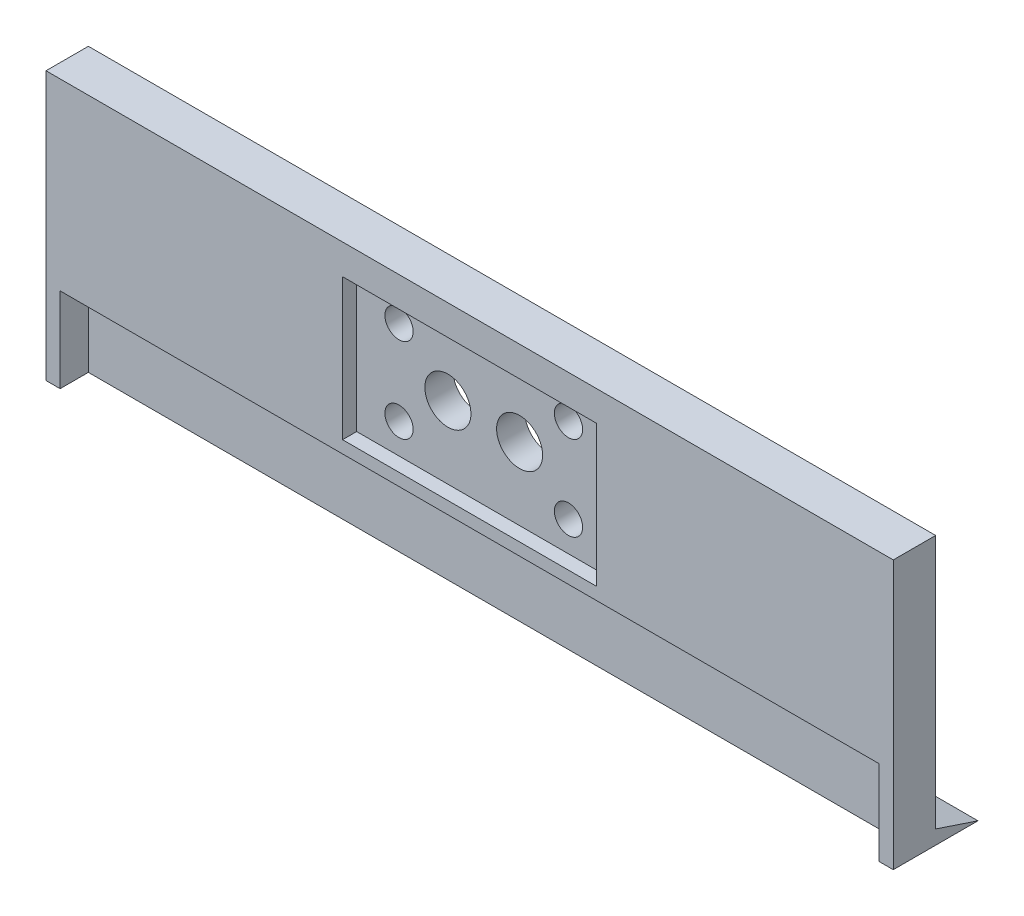
from build123d import *

# Parameters (mm, degrees)
ESQUISSE1_W             = 300
ESQUISSE1_H             = 95
BOSS_EXTRU_1_DEPTH      = 5
BOSS_EXTRU_2_DEPTH      = 300
BOSS_EXTRU_3_DEPTH      = 10
ESQUISSE6_R             = 8.15
ESQUISSE6_R_2           = 5
ENL_V_MAT_EXTRU_2_DEPTH = 16
ESQUISSE7_W             = 290
ESQUISSE7_H             = 23.020862504
ENL_V_MAT_EXTRU_3_DEPTH = 30
ESQUISSE9_W             = 90
ESQUISSE9_H             = 50
ENL_V_MAT_EXTRU_4_DEPTH = 5


with BuildPart() as part:
    # Esquisse1 → Boss.-Extru.1 (new body)
    with BuildSketch(Plane.XY):
        with Locations((150, 47.5)):
            Rectangle(ESQUISSE1_W, ESQUISSE1_H)
    extrude(amount=BOSS_EXTRU_1_DEPTH)

    # Esquisse3 → Boss.-Extru.2 (add)
    with BuildSketch(Plane.ZY):
        Polygon((-15, 0), (0, 0), (0, 5), align=None)
    extrude(amount=-BOSS_EXTRU_2_DEPTH)

    # Esquisse5 → Boss.-Extru.3 (add)
    with BuildSketch(Plane.XY.offset(5)):
        Polygon((195, 95), (105, 95), (0, 95), (0, 30), (0, 0), (300, 0), (300, 30), (300, 95), align=None)
    extrude(amount=BOSS_EXTRU_3_DEPTH)

    # Esquisse6 → Enlèv. mat.-Extru.2 (cut, through all)
    with BuildSketch(Plane(origin=(0, 0, 0), x_dir=(-1, 0, 0), z_dir=(0, 0, -1))):
        with Locations((-162.7, 60)):
            Circle(ESQUISSE6_R)
        with Locations((-137.3, 60)):
            Circle(ESQUISSE6_R)
        with Locations((-180, 75)):
            Circle(ESQUISSE6_R_2)
        with Locations((-180, 45)):
            Circle(ESQUISSE6_R_2)
        with Locations((-120, 75)):
            Circle(ESQUISSE6_R_2)
        with Locations((-120, 45)):
            Circle(ESQUISSE6_R_2)
    extrude(amount=-ENL_V_MAT_EXTRU_2_DEPTH, mode=Mode.SUBTRACT)

    # Esquisse7 → Enlèv. mat.-Extru.3 (cut)
    with BuildSketch(Plane.XZ):
        with Locations((150, 16.510431252)):
            Rectangle(ESQUISSE7_W, ESQUISSE7_H)
    extrude(amount=-ENL_V_MAT_EXTRU_3_DEPTH, mode=Mode.SUBTRACT)

    # Esquisse9 → Enlèv. mat.-Extru.4 (cut)
    with BuildSketch(Plane.XY.offset(15)):
        with Locations((150, 59.36084713)):
            Rectangle(ESQUISSE9_W, ESQUISSE9_H)
    extrude(amount=-ENL_V_MAT_EXTRU_4_DEPTH, mode=Mode.SUBTRACT)


solid = part.part
